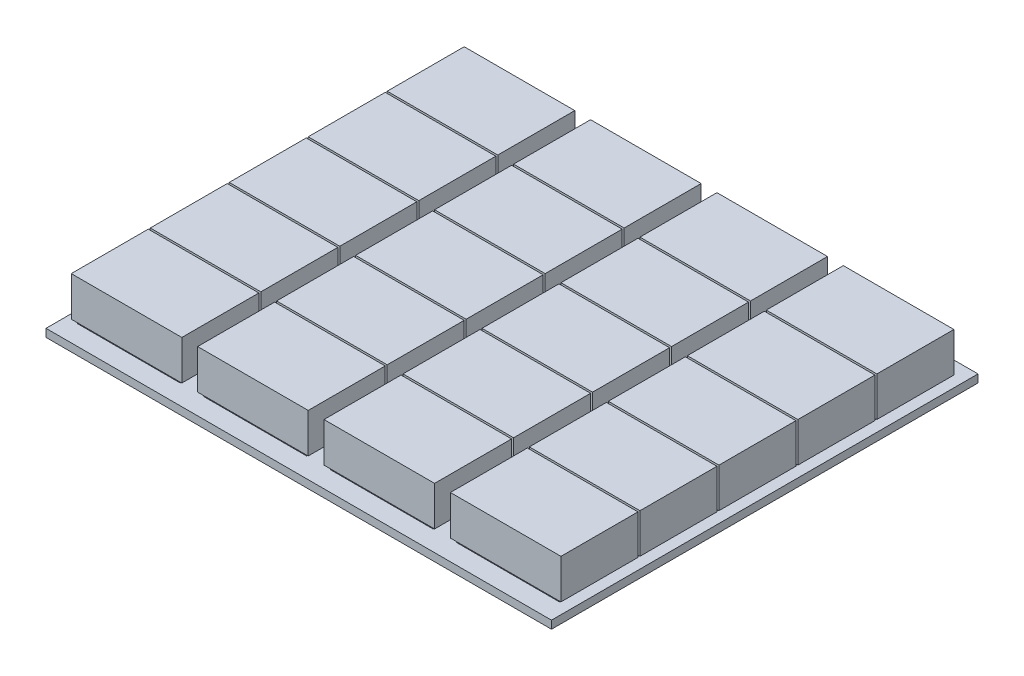
from build123d import *

# Parameters (mm, degrees)
SKETCH1_W                  = 80
SKETCH1_H                  = 270
BOSS_EXTRUDE1_DEPTH        = 5
SKETCH2_W                  = 65
SKETCH2_H                  = 45
BOSS_EXTRUDE3_DEPTH        = 2
LPATTERN1_COUNT            = 5
LPATTERN1_PITCH            = 50
SKETCH3_W                  = 70
SKETCH3_H                  = 48.748964222
BOSS_EXTRUDE8_DEPTH        = 25
LPATTERN5_COUNT            = 5
LPATTERN5_PITCH            = 50
LPATTERN6_COUNT            = 4
LPATTERN6_PITCH            = 80
LPATTERN6_COPY_1_SKETCH_W  = 65
LPATTERN6_COPY_1_SKETCH_H  = 45
LPATTERN6_COPY_1_DEPTH     = 2
LPATTERN6_COPY_2_SKETCH_W  = 65
LPATTERN6_COPY_2_SKETCH_H  = 45
LPATTERN6_COPY_2_DEPTH     = 2
LPATTERN6_COPY_3_SKETCH_W  = 65
LPATTERN6_COPY_3_SKETCH_H  = 45
LPATTERN6_COPY_3_DEPTH     = 2
LPATTERN6_COPY_4_SKETCH_W  = 65
LPATTERN6_COPY_4_SKETCH_H  = 45
LPATTERN6_COPY_4_DEPTH     = 2
LPATTERN6_COPY_5_SKETCH_W  = 65
LPATTERN6_COPY_5_SKETCH_H  = 45
LPATTERN6_COPY_5_DEPTH     = 2
LPATTERN6_COPY_6_SKETCH_W  = 65
LPATTERN6_COPY_6_SKETCH_H  = 45
LPATTERN6_COPY_6_DEPTH     = 2
LPATTERN6_COPY_7_SKETCH_W  = 65
LPATTERN6_COPY_7_SKETCH_H  = 45
LPATTERN6_COPY_7_DEPTH     = 2
LPATTERN6_COPY_8_SKETCH_W  = 65
LPATTERN6_COPY_8_SKETCH_H  = 45
LPATTERN6_COPY_8_DEPTH     = 2
LPATTERN6_COPY_9_SKETCH_W  = 65
LPATTERN6_COPY_9_SKETCH_H  = 45
LPATTERN6_COPY_9_DEPTH     = 2
LPATTERN6_COPY_10_SKETCH_W = 65
LPATTERN6_COPY_10_SKETCH_H = 45
LPATTERN6_COPY_10_DEPTH    = 2
LPATTERN6_COPY_11_SKETCH_W = 65
LPATTERN6_COPY_11_SKETCH_H = 45
LPATTERN6_COPY_11_DEPTH    = 2
LPATTERN6_COPY_12_SKETCH_W = 65
LPATTERN6_COPY_12_SKETCH_H = 45
LPATTERN6_COPY_12_DEPTH    = 2
LPATTERN6_COPY_13_SKETCH_W = 70
LPATTERN6_COPY_13_SKETCH_H = 48.748964222
LPATTERN6_COPY_13_DEPTH    = 25
LPATTERN6_COPY_14_SKETCH_W = 70
LPATTERN6_COPY_14_SKETCH_H = 48.748964222
LPATTERN6_COPY_14_DEPTH    = 25
LPATTERN6_COPY_15_SKETCH_W = 70
LPATTERN6_COPY_15_SKETCH_H = 48.748964222
LPATTERN6_COPY_15_DEPTH    = 25
LPATTERN6_COPY_16_SKETCH_W = 70
LPATTERN6_COPY_16_SKETCH_H = 48.748964222
LPATTERN6_COPY_16_DEPTH    = 25
LPATTERN6_COPY_17_SKETCH_W = 70
LPATTERN6_COPY_17_SKETCH_H = 48.748964222
LPATTERN6_COPY_17_DEPTH    = 25
LPATTERN6_COPY_18_SKETCH_W = 70
LPATTERN6_COPY_18_SKETCH_H = 48.748964222
LPATTERN6_COPY_18_DEPTH    = 25
LPATTERN6_COPY_19_SKETCH_W = 70
LPATTERN6_COPY_19_SKETCH_H = 48.748964222
LPATTERN6_COPY_19_DEPTH    = 25
LPATTERN6_COPY_20_SKETCH_W = 70
LPATTERN6_COPY_20_SKETCH_H = 48.748964222
LPATTERN6_COPY_20_DEPTH    = 25
LPATTERN6_COPY_21_SKETCH_W = 70
LPATTERN6_COPY_21_SKETCH_H = 48.748964222
LPATTERN6_COPY_21_DEPTH    = 25
LPATTERN6_COPY_22_SKETCH_W = 70
LPATTERN6_COPY_22_SKETCH_H = 48.748964222
LPATTERN6_COPY_22_DEPTH    = 25
LPATTERN6_COPY_23_SKETCH_W = 70
LPATTERN6_COPY_23_SKETCH_H = 48.748964222
LPATTERN6_COPY_23_DEPTH    = 25
LPATTERN6_COPY_24_SKETCH_W = 70
LPATTERN6_COPY_24_SKETCH_H = 48.748964222
LPATTERN6_COPY_24_DEPTH    = 25


with BuildPart() as part:
    # Sketch1 → Boss-Extrude1 (new body)
    with BuildSketch(Plane(origin=(0, 0, 0), x_dir=(1, 0, 0), z_dir=(0, 1, 0))):
        Rectangle(SKETCH1_W, SKETCH1_H)
    boss_extrude1 = extrude(amount=BOSS_EXTRUDE1_DEPTH)

    # Sketch2 → Boss-Extrude3 (add)
    with BuildSketch(Plane(origin=(0, 5, 0), x_dir=(1, 0, 0), z_dir=(0, 1, 0))):
        with Locations((0, -100)):
            Rectangle(SKETCH2_W, SKETCH2_H)
    boss_extrude3 = extrude(amount=BOSS_EXTRUDE3_DEPTH)

    # LPattern1: Boss-Extrude3 ×5
    with Locations(*[(0, 0, -i * LPATTERN1_PITCH) for i in range(1, LPATTERN1_COUNT)]):
        add(boss_extrude3)

    # Sketch3 → Boss-Extrude8 (add)
    with BuildSketch(Plane(origin=(0, 7, 0), x_dir=(1, 0, 0), z_dir=(0, 1, 0))):
        with Locations((0, -99.635002086)):
            Rectangle(SKETCH3_W, SKETCH3_H)
    boss_extrude8 = extrude(amount=BOSS_EXTRUDE8_DEPTH)

    # LPattern5: Boss-Extrude8 ×5
    with Locations(*[(0, 0, -i * LPATTERN5_PITCH) for i in range(1, LPATTERN5_COUNT)]):
        add(boss_extrude8)

    # LPattern6: Boss-Extrude1, Boss-Extrude3, Boss-Extrude8 ×4
    with Locations(*[(-i * LPATTERN6_PITCH, 0, 0) for i in range(1, LPATTERN6_COUNT)]):
        add(boss_extrude1)
        add(boss_extrude3)
        add(boss_extrude8)

    # LPattern6 copy 1 sketch → LPattern6 copy 1 (add)
    with BuildSketch(Plane(origin=(-80, 5, -50), x_dir=(1, 0, 0), z_dir=(0, 1, 0))):
        with Locations((0, -100)):
            Rectangle(LPATTERN6_COPY_1_SKETCH_W, LPATTERN6_COPY_1_SKETCH_H)
    extrude(amount=LPATTERN6_COPY_1_DEPTH)

    # LPattern6 copy 2 sketch → LPattern6 copy 2 (add)
    with BuildSketch(Plane(origin=(-160, 5, -50), x_dir=(1, 0, 0), z_dir=(0, 1, 0))):
        with Locations((0, -100)):
            Rectangle(LPATTERN6_COPY_2_SKETCH_W, LPATTERN6_COPY_2_SKETCH_H)
    extrude(amount=LPATTERN6_COPY_2_DEPTH)

    # LPattern6 copy 3 sketch → LPattern6 copy 3 (add)
    with BuildSketch(Plane(origin=(-240, 5, -50), x_dir=(1, 0, 0), z_dir=(0, 1, 0))):
        with Locations((0, -100)):
            Rectangle(LPATTERN6_COPY_3_SKETCH_W, LPATTERN6_COPY_3_SKETCH_H)
    extrude(amount=LPATTERN6_COPY_3_DEPTH)

    # LPattern6 copy 4 sketch → LPattern6 copy 4 (add)
    with BuildSketch(Plane(origin=(-80, 5, -100), x_dir=(1, 0, 0), z_dir=(0, 1, 0))):
        with Locations((0, -100)):
            Rectangle(LPATTERN6_COPY_4_SKETCH_W, LPATTERN6_COPY_4_SKETCH_H)
    extrude(amount=LPATTERN6_COPY_4_DEPTH)

    # LPattern6 copy 5 sketch → LPattern6 copy 5 (add)
    with BuildSketch(Plane(origin=(-160, 5, -100), x_dir=(1, 0, 0), z_dir=(0, 1, 0))):
        with Locations((0, -100)):
            Rectangle(LPATTERN6_COPY_5_SKETCH_W, LPATTERN6_COPY_5_SKETCH_H)
    extrude(amount=LPATTERN6_COPY_5_DEPTH)

    # LPattern6 copy 6 sketch → LPattern6 copy 6 (add)
    with BuildSketch(Plane(origin=(-240, 5, -100), x_dir=(1, 0, 0), z_dir=(0, 1, 0))):
        with Locations((0, -100)):
            Rectangle(LPATTERN6_COPY_6_SKETCH_W, LPATTERN6_COPY_6_SKETCH_H)
    extrude(amount=LPATTERN6_COPY_6_DEPTH)

    # LPattern6 copy 7 sketch → LPattern6 copy 7 (add)
    with BuildSketch(Plane(origin=(-80, 5, -150), x_dir=(1, 0, 0), z_dir=(0, 1, 0))):
        with Locations((0, -100)):
            Rectangle(LPATTERN6_COPY_7_SKETCH_W, LPATTERN6_COPY_7_SKETCH_H)
    extrude(amount=LPATTERN6_COPY_7_DEPTH)

    # LPattern6 copy 8 sketch → LPattern6 copy 8 (add)
    with BuildSketch(Plane(origin=(-160, 5, -150), x_dir=(1, 0, 0), z_dir=(0, 1, 0))):
        with Locations((0, -100)):
            Rectangle(LPATTERN6_COPY_8_SKETCH_W, LPATTERN6_COPY_8_SKETCH_H)
    extrude(amount=LPATTERN6_COPY_8_DEPTH)

    # LPattern6 copy 9 sketch → LPattern6 copy 9 (add)
    with BuildSketch(Plane(origin=(-240, 5, -150), x_dir=(1, 0, 0), z_dir=(0, 1, 0))):
        with Locations((0, -100)):
            Rectangle(LPATTERN6_COPY_9_SKETCH_W, LPATTERN6_COPY_9_SKETCH_H)
    extrude(amount=LPATTERN6_COPY_9_DEPTH)

    # LPattern6 copy 10 sketch → LPattern6 copy 10 (add)
    with BuildSketch(Plane(origin=(-80, 5, -200), x_dir=(1, 0, 0), z_dir=(0, 1, 0))):
        with Locations((0, -100)):
            Rectangle(LPATTERN6_COPY_10_SKETCH_W, LPATTERN6_COPY_10_SKETCH_H)
    extrude(amount=LPATTERN6_COPY_10_DEPTH)

    # LPattern6 copy 11 sketch → LPattern6 copy 11 (add)
    with BuildSketch(Plane(origin=(-160, 5, -200), x_dir=(1, 0, 0), z_dir=(0, 1, 0))):
        with Locations((0, -100)):
            Rectangle(LPATTERN6_COPY_11_SKETCH_W, LPATTERN6_COPY_11_SKETCH_H)
    extrude(amount=LPATTERN6_COPY_11_DEPTH)

    # LPattern6 copy 12 sketch → LPattern6 copy 12 (add)
    with BuildSketch(Plane(origin=(-240, 5, -200), x_dir=(1, 0, 0), z_dir=(0, 1, 0))):
        with Locations((0, -100)):
            Rectangle(LPATTERN6_COPY_12_SKETCH_W, LPATTERN6_COPY_12_SKETCH_H)
    extrude(amount=LPATTERN6_COPY_12_DEPTH)

    # LPattern6 copy 13 sketch → LPattern6 copy 13 (add)
    with BuildSketch(Plane(origin=(-80, 7, -50), x_dir=(1, 0, 0), z_dir=(0, 1, 0))):
        with Locations((0, -99.635002086)):
            Rectangle(LPATTERN6_COPY_13_SKETCH_W, LPATTERN6_COPY_13_SKETCH_H)
    extrude(amount=LPATTERN6_COPY_13_DEPTH)

    # LPattern6 copy 14 sketch → LPattern6 copy 14 (add)
    with BuildSketch(Plane(origin=(-160, 7, -50), x_dir=(1, 0, 0), z_dir=(0, 1, 0))):
        with Locations((0, -99.635002086)):
            Rectangle(LPATTERN6_COPY_14_SKETCH_W, LPATTERN6_COPY_14_SKETCH_H)
    extrude(amount=LPATTERN6_COPY_14_DEPTH)

    # LPattern6 copy 15 sketch → LPattern6 copy 15 (add)
    with BuildSketch(Plane(origin=(-240, 7, -50), x_dir=(1, 0, 0), z_dir=(0, 1, 0))):
        with Locations((0, -99.635002086)):
            Rectangle(LPATTERN6_COPY_15_SKETCH_W, LPATTERN6_COPY_15_SKETCH_H)
    extrude(amount=LPATTERN6_COPY_15_DEPTH)

    # LPattern6 copy 16 sketch → LPattern6 copy 16 (add)
    with BuildSketch(Plane(origin=(-80, 7, -100), x_dir=(1, 0, 0), z_dir=(0, 1, 0))):
        with Locations((0, -99.635002086)):
            Rectangle(LPATTERN6_COPY_16_SKETCH_W, LPATTERN6_COPY_16_SKETCH_H)
    extrude(amount=LPATTERN6_COPY_16_DEPTH)

    # LPattern6 copy 17 sketch → LPattern6 copy 17 (add)
    with BuildSketch(Plane(origin=(-160, 7, -100), x_dir=(1, 0, 0), z_dir=(0, 1, 0))):
        with Locations((0, -99.635002086)):
            Rectangle(LPATTERN6_COPY_17_SKETCH_W, LPATTERN6_COPY_17_SKETCH_H)
    extrude(amount=LPATTERN6_COPY_17_DEPTH)

    # LPattern6 copy 18 sketch → LPattern6 copy 18 (add)
    with BuildSketch(Plane(origin=(-240, 7, -100), x_dir=(1, 0, 0), z_dir=(0, 1, 0))):
        with Locations((0, -99.635002086)):
            Rectangle(LPATTERN6_COPY_18_SKETCH_W, LPATTERN6_COPY_18_SKETCH_H)
    extrude(amount=LPATTERN6_COPY_18_DEPTH)

    # LPattern6 copy 19 sketch → LPattern6 copy 19 (add)
    with BuildSketch(Plane(origin=(-80, 7, -150), x_dir=(1, 0, 0), z_dir=(0, 1, 0))):
        with Locations((0, -99.635002086)):
            Rectangle(LPATTERN6_COPY_19_SKETCH_W, LPATTERN6_COPY_19_SKETCH_H)
    extrude(amount=LPATTERN6_COPY_19_DEPTH)

    # LPattern6 copy 20 sketch → LPattern6 copy 20 (add)
    with BuildSketch(Plane(origin=(-160, 7, -150), x_dir=(1, 0, 0), z_dir=(0, 1, 0))):
        with Locations((0, -99.635002086)):
            Rectangle(LPATTERN6_COPY_20_SKETCH_W, LPATTERN6_COPY_20_SKETCH_H)
    extrude(amount=LPATTERN6_COPY_20_DEPTH)

    # LPattern6 copy 21 sketch → LPattern6 copy 21 (add)
    with BuildSketch(Plane(origin=(-240, 7, -150), x_dir=(1, 0, 0), z_dir=(0, 1, 0))):
        with Locations((0, -99.635002086)):
            Rectangle(LPATTERN6_COPY_21_SKETCH_W, LPATTERN6_COPY_21_SKETCH_H)
    extrude(amount=LPATTERN6_COPY_21_DEPTH)

    # LPattern6 copy 22 sketch → LPattern6 copy 22 (add)
    with BuildSketch(Plane(origin=(-80, 7, -200), x_dir=(1, 0, 0), z_dir=(0, 1, 0))):
        with Locations((0, -99.635002086)):
            Rectangle(LPATTERN6_COPY_22_SKETCH_W, LPATTERN6_COPY_22_SKETCH_H)
    extrude(amount=LPATTERN6_COPY_22_DEPTH)

    # LPattern6 copy 23 sketch → LPattern6 copy 23 (add)
    with BuildSketch(Plane(origin=(-160, 7, -200), x_dir=(1, 0, 0), z_dir=(0, 1, 0))):
        with Locations((0, -99.635002086)):
            Rectangle(LPATTERN6_COPY_23_SKETCH_W, LPATTERN6_COPY_23_SKETCH_H)
    extrude(amount=LPATTERN6_COPY_23_DEPTH)

    # LPattern6 copy 24 sketch → LPattern6 copy 24 (add)
    with BuildSketch(Plane(origin=(-240, 7, -200), x_dir=(1, 0, 0), z_dir=(0, 1, 0))):
        with Locations((0, -99.635002086)):
            Rectangle(LPATTERN6_COPY_24_SKETCH_W, LPATTERN6_COPY_24_SKETCH_H)
    extrude(amount=LPATTERN6_COPY_24_DEPTH)


solid = part.part
